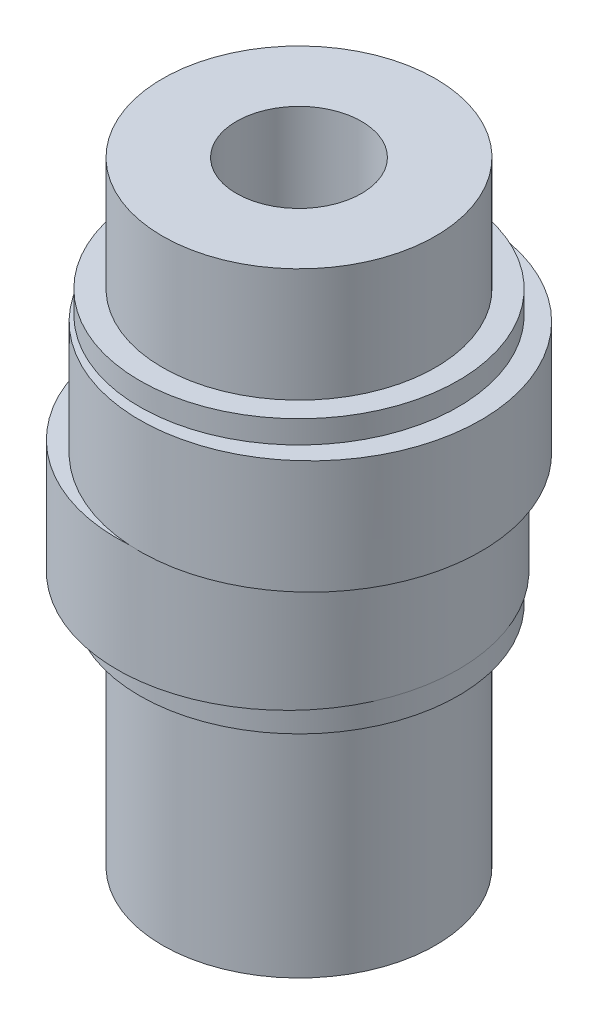
from build123d import *

# Parameters (mm, degrees)
SKETCH1_R           = 7.5
DISK1_DEPTH         = 5
SKETCH2_R           = 7.5
DISK2_DEPTH         = 5
SKETCH3_R           = 7
TAP_GAP_DEPTH       = 1
SKETCH4_R           = 6
TOP_BEARING_DEPTH   = 5
SHAFTMOUNT_R        = 7
GAP_DEPTH           = 1
SKETCH8_R           = 6
BEARING_DEPTH       = 5
SKETCH9_R           = 6
SKETCH9_R_2         = 5
BOSS_EXTRUDE2_DEPTH = 5
SKETCH7_R           = 2.75
HOLECUT_DEPTH       = 20.397164741
HOLECUT_DEPTH_BACK  = 20.397164741


with BuildPart() as part:
    # Sketch1 → disk1 (new body)
    with BuildSketch(Plane(origin=(0, 0, 0), x_dir=(1, 0, 0), z_dir=(0, 1, 0))):
        with Locations(Location((-0.5, 0, 0), (0, 0, 270))):
            Circle(SKETCH1_R)
    extrude(amount=DISK1_DEPTH)

    # Sketch2 → disk2 (add)
    with BuildSketch(Plane(origin=(0, 5, 0), x_dir=(1, 0, 0), z_dir=(0, 1, 0))):
        with Locations(Location((0.5, 0, 0), (0, 0, 93.822553729))):
            Circle(SKETCH2_R)
    extrude(amount=DISK2_DEPTH)

    # Sketch3 → tap-gap (add)
    with BuildSketch(Plane(origin=(0, 10, 0), x_dir=(1, 0, 0), z_dir=(0, 1, 0))):
        with Locations(Location((0, 0, 0), (0, 0, 180))):
            Circle(SKETCH3_R)
    extrude(amount=TAP_GAP_DEPTH)

    # Sketch4 → top-bearing (add)
    with BuildSketch(Plane(origin=(0, 11, 0), x_dir=(1, 0, 0), z_dir=(0, 1, 0))):
        with Locations(Location((0, 0, 0), (0, 0, 270))):
            Circle(SKETCH4_R)
    extrude(amount=TOP_BEARING_DEPTH)

    # shaftmount → gap (add)
    with BuildSketch(Plane(origin=(0, 0, 0), x_dir=(1, 0, 0), z_dir=(0, 1, 0))):
        with Locations(Location((0, 0, 0), (0, 0, 180))):
            Circle(SHAFTMOUNT_R)
    extrude(amount=-GAP_DEPTH)

    # Sketch8 → bearing (add)
    with BuildSketch(Plane.XZ.offset(1)):
        with Locations(Location((0, 0, 0), (0, 0, 90))):
            Circle(SKETCH8_R)
    extrude(amount=BEARING_DEPTH)

    # Sketch9 → Boss-Extrude2 (add)
    with BuildSketch(Plane.XZ.offset(6)):
        with Locations(Location((0, 0, 0), (0, 0, 90))):
            Circle(SKETCH9_R)
        Circle(SKETCH9_R_2, mode=Mode.SUBTRACT)
        with BuildLine():
            Line((-3, -4), (-3, 4))
            ThreePointArc((-3, 4), (-5, 0), (-3, -4))
        make_face()
    extrude(amount=BOSS_EXTRUDE2_DEPTH)

    # Sketch7 → holeCut (cut, two sides)
    with BuildSketch(Plane(origin=(0, 0, 0), x_dir=(1, 0, 0), z_dir=(0, 1, 0))) as holecut_sk:
        with Locations(Location((0, 0, 0), (0, 0, 270))):
            Circle(SKETCH7_R)
    extrude(amount=HOLECUT_DEPTH, mode=Mode.SUBTRACT)
    extrude(holecut_sk.sketch, amount=-HOLECUT_DEPTH_BACK, mode=Mode.SUBTRACT)


solid = part.part
